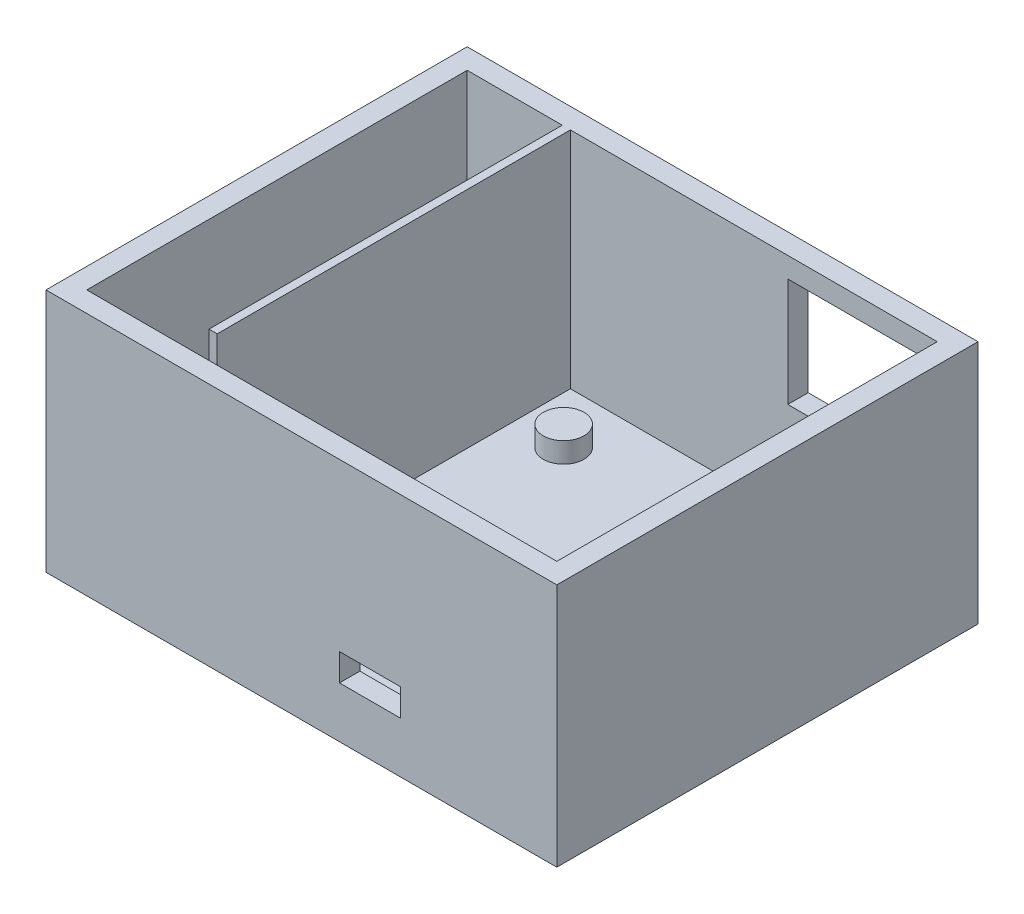
from build123d import *

# Parameters (mm, degrees)
SKETCH1_W           = 75.2
SKETCH1_H           = 62
SKETCH1_W_2         = 54
SKETCH1_H_2         = 56
SKETCH1_R           = 3
SKETCH1_W_3         = 1.2
SKETCH1_W_4         = 14
BOSS_EXTRUDE1_DEPTH = 3
BOSS_EXTRUDE2_START = 3
SKETCH1_3_R         = 3
BOSS_EXTRUDE2_DEPTH = 3
BOSS_EXTRUDE3_START = 3
SKETCH1_4_W         = 75.2
SKETCH1_4_H         = 62
SKETCH1_4_W_2       = 1.2
SKETCH1_4_H_2       = 56
BOSS_EXTRUDE3_DEPTH = 33
CUT_EXTRUDE1_REACH  = 103.749
SKETCH2_W           = 9
SKETCH2_H           = 4
CUT_EXTRUDE2_REACH  = 92.356
SKETCH3_W           = 4
SKETCH3_H           = 12
CUT_EXTRUDE3_REACH  = 103.749
SKETCH4_W           = 20
SKETCH4_H           = 16


with BuildPart() as part:
    # Sketch1 → Boss-Extrude1 (new body)
    with BuildSketch(Plane(origin=(0, 0, 0), x_dir=(1, 0, 0), z_dir=(0, 1, 0))):
        with Locations((-34.6, -28)):
            Rectangle(SKETCH1_W, SKETCH1_H)
        Polygon((-55.2, -56), (-54, -56), (0, -56), (0, 0), (-54, 0), (-55.2, 0), (-69.2, 0), (-69.2, -56), align=None, mode=Mode.SUBTRACT)
        with Locations((-27, -28)):
            Rectangle(SKETCH1_W_2, SKETCH1_H_2)
        with Locations((-47, -50)):
            Circle(SKETCH1_R, mode=Mode.SUBTRACT)
        with Locations((-5, -50)):
            Circle(SKETCH1_R, mode=Mode.SUBTRACT)
        with Locations((-5, -8)):
            Circle(SKETCH1_R, mode=Mode.SUBTRACT)
        with Locations((-47, -8)):
            Circle(SKETCH1_R, mode=Mode.SUBTRACT)
        with Locations((-47, -50)):
            Circle(SKETCH1_R)
        with Locations((-5, -50)):
            Circle(SKETCH1_R)
        with Locations((-5, -8)):
            Circle(SKETCH1_R)
        with Locations((-47, -8)):
            Circle(SKETCH1_R)
        with Locations((-54.6, -28)):
            Rectangle(SKETCH1_W_3, SKETCH1_H_2)
        with Locations((-62.2, -28)):
            Rectangle(SKETCH1_W_4, SKETCH1_H_2)
    extrude(amount=BOSS_EXTRUDE1_DEPTH)

    # Sketch1_3 → Boss-Extrude2 (add)
    with BuildSketch(Plane(origin=(0, 0, 0), x_dir=(1, 0, 0), z_dir=(0, 1, 0)).offset(BOSS_EXTRUDE2_START)):
        with Locations(Location((-47, -50, 0), (0, 0, 270))):
            Circle(SKETCH1_3_R)
        with Locations(Location((-5, -50, 0), (0, 0, 270))):
            Circle(SKETCH1_3_R)
        with Locations(Location((-5, -8, 0), (0, 0, 270))):
            Circle(SKETCH1_3_R)
        with Locations(Location((-47, -8, 0), (0, 0, 270))):
            Circle(SKETCH1_3_R)
    extrude(amount=BOSS_EXTRUDE2_DEPTH)

    # Sketch1_4 → Boss-Extrude3 (add)
    with BuildSketch(Plane(origin=(0, 0, 0), x_dir=(1, 0, 0), z_dir=(0, 1, 0)).offset(BOSS_EXTRUDE3_START)):
        with Locations((-34.6, -28)):
            Rectangle(SKETCH1_4_W, SKETCH1_4_H)
        Polygon((-55.2, -56), (-54, -56), (0, -56), (0, 0), (-54, 0), (-55.2, 0), (-69.2, 0), (-69.2, -56), align=None, mode=Mode.SUBTRACT)
        with Locations((-54.6, -28)):
            Rectangle(SKETCH1_4_W_2, SKETCH1_4_H_2)
    extrude(amount=BOSS_EXTRUDE3_DEPTH)

    # Sketch2 → Cut-Extrude1 (cut, up to next)
    with BuildSketch(Plane.XY.offset(59), mode=Mode.PRIVATE) as cut_extrude1_sk1:
        with Locations((-24.5, 9.5)):
            Rectangle(SKETCH2_W, SKETCH2_H)
    cut_extrude1_tool1 = extrude(cut_extrude1_sk1.sketch, amount=-CUT_EXTRUDE1_REACH, mode=Mode.PRIVATE) & part.part
    add(cut_extrude1_tool1.solids().sort_by_distance((-24.5, 9.5, 59))[0], mode=Mode.SUBTRACT)

    # Sketch3 → Cut-Extrude2 (cut, up to next)
    with BuildSketch(Plane.ZY.offset(55.2), mode=Mode.PRIVATE) as cut_extrude2_sk1:
        with Locations((54, 30)):
            Rectangle(SKETCH3_W, SKETCH3_H)
    cut_extrude2_tool1 = extrude(cut_extrude2_sk1.sketch, amount=-CUT_EXTRUDE2_REACH, mode=Mode.PRIVATE) & part.part
    add(cut_extrude2_tool1.solids().sort_by_distance((-55.2, 30, 54))[0], mode=Mode.SUBTRACT)

    # Sketch4 → Cut-Extrude3 (cut, up to next)
    with BuildSketch(Plane(origin=(0, 0, -3), x_dir=(-1, 0, 0), z_dir=(0, 0, -1)), mode=Mode.PRIVATE) as cut_extrude3_sk1:
        with Locations((12, 25)):
            Rectangle(SKETCH4_W, SKETCH4_H)
    cut_extrude3_tool1 = extrude(cut_extrude3_sk1.sketch, amount=-CUT_EXTRUDE3_REACH, mode=Mode.PRIVATE) & part.part
    add(cut_extrude3_tool1.solids().sort_by_distance((-12, 25, -3))[0], mode=Mode.SUBTRACT)


solid = part.part
